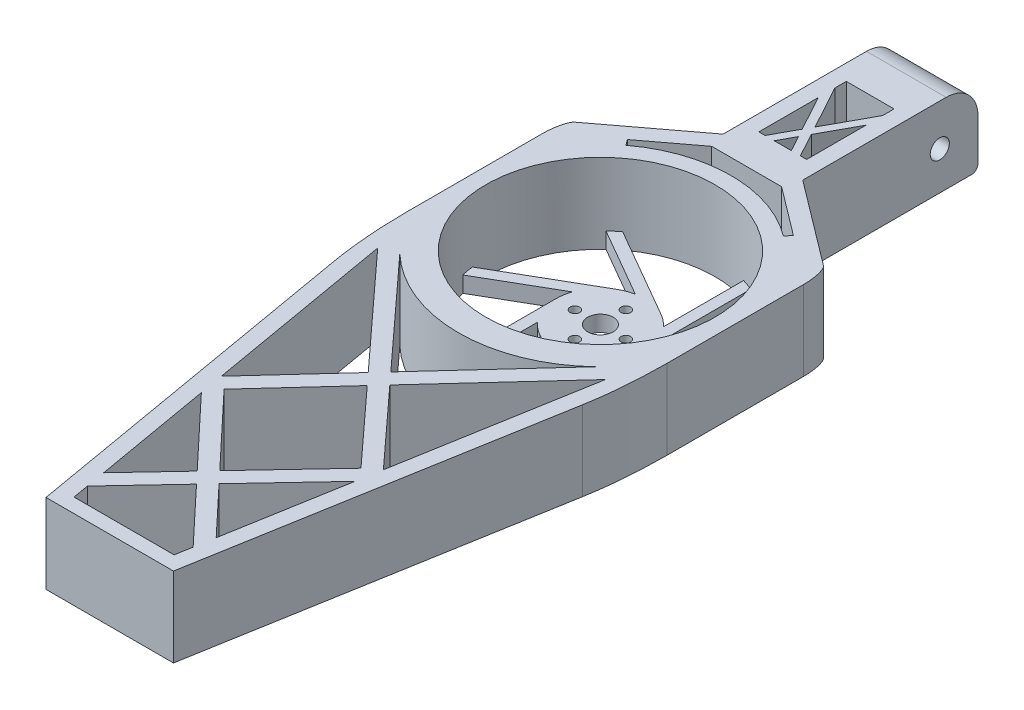
from build123d import *
from build123d.topology import SkipClean

# Parameters (mm, degrees)
SZKIC1_R                    = 1.5
SZKIC1_R_2                  = 4
DODANIE_WYCI_GNI_CIE1_DEPTH = 5
SZKIC1_3_R                  = 36
DODANIE_WYCI_GNI_CIE2_DEPTH = 25
ZAOKR_GLENIE1_R             = 10
ZAOKR_GLENIE2_R             = 2
SZKIC3_R                    = 3
WYTNIJ_WYCI_GNI_CIE2_DEPTH  = 220.010630871
WYTNIJ_WYCI_GNI_CIE3_DEPTH  = 216.983000337
WYTNIJ_WYCI_GNI_CIE4_DEPTH  = 217.503248093
WYTNIJ_WYCI_GNI_CIE5_DEPTH  = 217.503248093
DODANIE_WYCI_GNI_CIE3_DEPTH = 25


with BuildPart() as part:
    # Szkic1 → Dodanie-wyci_gni_cie1 (new body)
    with BuildSketch(Plane(origin=(0, 0, 0), x_dir=(1, 0, 0), z_dir=(0, 1, 0))):
        Polygon((-39.5, 60.773175281), (-20.5, -48.6036745), (19.5, -48.6036745), (38.5, 60.773175281), (38.5, 136.3963255), (12, 156.3963255), (12, 211.3963255), (-13, 211.3963255), (-13, 156.3963255), (-39.5, 136.3963255), align=None)
        with BuildLine():
            ThreePointArc((24.198683142, 138.122080663), (-0.5, 146.3963255), (-25.198683142, 138.122080663))
            Line((-25.198683142, 138.122080663), (-26.54670895, 139.908214858))
            Line((-26.54670895, 139.908214858), (-11.466042799, 151.289849688))
            Line((-11.466042799, 151.289849688), (10.466042799, 151.289849688))
            Line((10.466042799, 151.289849688), (25.54670895, 139.908214858))
            Line((25.54670895, 139.908214858), (24.198683142, 138.122080663))
        make_face(mode=Mode.SUBTRACT)
        with Locations((7.5, 105.3963255)):
            Circle(SZKIC1_R, mode=Mode.SUBTRACT)
        with Locations((-0.5, 97.3963255)):
            Circle(SZKIC1_R, mode=Mode.SUBTRACT)
        with Locations((-8.5, 105.3963255)):
            Circle(SZKIC1_R, mode=Mode.SUBTRACT)
        with Locations((-0.5, 105.3963255)):
            Circle(SZKIC1_R_2, mode=Mode.SUBTRACT)
        with Locations((-0.5, 113.3963255)):
            Circle(SZKIC1_R, mode=Mode.SUBTRACT)
    extrude(amount=DODANIE_WYCI_GNI_CIE1_DEPTH)

    # Szkic1_3 → Dodanie-wyci_gni_cie2 (add)
    with BuildSketch(Plane(origin=(0, 0, 0), x_dir=(1, 0, 0), z_dir=(0, 1, 0))):
        Polygon((-39.5, 60.773175281), (-20.5, -48.6036745), (19.5, -48.6036745), (38.5, 60.773175281), (38.5, 136.3963255), (12, 156.3963255), (12, 211.3963255), (-13, 211.3963255), (-13, 156.3963255), (-39.5, 136.3963255), align=None)
        with Locations((-0.5, 105.3963255)):
            Circle(SZKIC1_3_R, mode=Mode.SUBTRACT)
        with BuildLine():
            ThreePointArc((24.198683142, 138.122080663), (-0.5, 146.3963255), (-25.198683142, 138.122080663))
            Line((-25.198683142, 138.122080663), (-26.54670895, 139.908214858))
            Line((-26.54670895, 139.908214858), (-11.466042799, 151.289849688))
            Line((-11.466042799, 151.289849688), (10.466042799, 151.289849688))
            Line((10.466042799, 151.289849688), (25.54670895, 139.908214858))
            Line((25.54670895, 139.908214858), (24.198683142, 138.122080663))
        make_face(mode=Mode.SUBTRACT)
    extrude(amount=DODANIE_WYCI_GNI_CIE2_DEPTH)

    # Zaokr_glenie1
    zaokr_glenie1_edges = [part.edges().sort_by_distance(p)[0] for p in [
        (-0.5, 25, -211.3963255),
    ]]
    fillet(zaokr_glenie1_edges, radius=ZAOKR_GLENIE1_R)

    # Zaokr_glenie2
    zaokr_glenie2_edges = [part.edges().sort_by_distance(p)[0] for p in [
        (-0.5, 0, -211.3963255),
    ]]
    fillet(zaokr_glenie2_edges, radius=ZAOKR_GLENIE2_R)

    # Szkic3 → Wytnij-wyci_gni_cie2 (cut, through all)
    with BuildSketch(Plane.ZY.offset(13)):
        with Locations((-199.3963255, 12)):
            Circle(SZKIC3_R)
    extrude(amount=-WYTNIJ_WYCI_GNI_CIE2_DEPTH, mode=Mode.SUBTRACT)

    # Szkic4 → Wytnij-wyci_gni_cie3 (cut, through all)
    with SkipClean():  # the faces are left unmerged after this step: merging them gives an invalid solid
        with BuildSketch(Plane(origin=(0, 5, 0), x_dir=(1, 0, 0), z_dir=(0, 1, 0))):
            with BuildLine():
                Line((13.5, 138.562573403), (13.5, 105.3963255))
                ThreePointArc((13.5, 105.3963255), (13.316169956, 103.135032123), (12.769507466, 100.933123554))
                Line((12.769507466, 100.933123554), (34.571343028, 113.520419185))
                ThreePointArc((34.571343028, 113.520419185), (27.045898944, 128.57440677), (13.5, 138.562573403))
            make_face()
            with BuildLine():
                ThreePointArc((6.5, 117.520681153), (8.366422488, 116.230832976), (10, 114.656455088))
                Line((10, 114.656455088), (10, 139.831046349))
                ThreePointArc((10, 139.831046349), (-6.799857719, 140.84081439), (-22.222813233, 134.103805104))
                Line((-22.222813233, 134.103805104), (6.5, 117.520681153))
            make_face()
            with BuildLine():
                Line((35.222813233, 109.855093798), (6.5, 93.271969847))
                ThreePointArc((6.5, 93.271969847), (4.449747468, 92.300524646), (2.269507466, 91.672993965))
                Line((2.269507466, 91.672993965), (24.071343028, 79.085698335))
                ThreePointArc((24.071343028, 79.085698335), (33.345756663, 93.129917879), (35.222813233, 109.855093798))
            make_face()
            with BuildLine():
                ThreePointArc((-7.5, 117.520681153), (-5.449747468, 118.492126353), (-3.269507466, 119.119657034))
                Line((-3.269507466, 119.119657034), (-25.071343028, 131.706952664))
                ThreePointArc((-25.071343028, 131.706952664), (-34.345756663, 117.66273312), (-36.222813233, 100.937557201))
                Line((-36.222813233, 100.937557201), (-7.5, 117.520681153))
            make_face()
            with BuildLine():
                Line((21.222813233, 76.688845895), (-7.5, 93.271969847))
                ThreePointArc((-7.5, 93.271969847), (-9.366422488, 94.561818023), (-11, 96.136195911))
                Line((-11, 96.136195911), (-11, 70.96160465))
                ThreePointArc((-11, 70.96160465), (5.799857719, 69.951836609), (21.222813233, 76.688845895))
            make_face()
            with BuildLine():
                ThreePointArc((-14.5, 105.3963255), (-14.316169956, 107.657618877), (-13.769507466, 109.859527445))
                Line((-13.769507466, 109.859527445), (-35.571343028, 97.272231814))
                ThreePointArc((-35.571343028, 97.272231814), (-28.045898944, 82.218244229), (-14.5, 72.230077596))
                Line((-14.5, 72.230077596), (-14.5, 105.3963255))
            make_face()
        extrude(amount=-WYTNIJ_WYCI_GNI_CIE3_DEPTH, mode=Mode.SUBTRACT)

    # Szkic5 → Wytnij-wyci_gni_cie4 (cut, through all)
    with SkipClean():  # the faces are left unmerged after this step: merging them gives an invalid solid
        with BuildSketch(Plane(origin=(0, 25, 0), x_dir=(1, 0, 0), z_dir=(0, 1, 0))):
            Polygon((-0.5, 167.537901521), (-3.188590085, 162.617610716), (2.188590085, 162.617610716), align=None)
            Polygon((-8, 162.617610716), (-6.037476669, 162.617610716), (-1.924443292, 170.144723317), (-8, 181.2633784), align=None)
            Polygon((0.924443292, 170.144723317), (5.037476669, 162.617610716), (7, 162.617610716), (7, 181.2633784), align=None)
            Polygon((-8, 186.477021992), (-0.5, 172.751545113), (7, 186.477021992), (7, 190.068564472), (-8, 190.068564472), align=None)
        extrude(amount=-WYTNIJ_WYCI_GNI_CIE4_DEPTH, mode=Mode.SUBTRACT)

    # Szkic6 → Wytnij-wyci_gni_cie5 (cut, through all)
    with SkipClean():  # the faces are left unmerged after this step: merging them gives an invalid solid
        with BuildSketch(Plane(origin=(0, 25, 0), x_dir=(1, 0, 0), z_dir=(0, 1, 0))):
            Polygon((2.890112786, 35.914234697), (24.927207854, 11.853436604), (35.243006097, 71.238147911), align=None)
            Polygon((2.931825406, -17.721341562), (17.161306881, -32.852341508), (23.609193637, 4.266055389), align=None)
            Polygon((-36.243006097, 71.238147911), (-25.927207854, 11.853436604), (-3.890112786, 35.914234697), align=None)
            Polygon((-24.609193637, 4.266055389), (-18.161306881, -32.852341508), (-3.931825406, -17.721341562), align=None)
            Polygon((-0.5, -21.370592599), (-17.091150305, -39.01288651), (-16.206822662, -44.1036745), (15.206822662, -44.1036745), (16.091150305, -39.01288651), align=None)
            Polygon((20.976041499, 8.764580183), (-0.5, 32.212802226), (-21.976041499, 8.764580183), (-0.5, -14.072090524), align=None)
            with BuildLine():
                Line((-31.262410293, 73.203040667), (-0.5, 39.615667168))
                Line((-0.5, 39.615667168), (30.262410293, 73.203040667))
                ThreePointArc((30.262410293, 73.203040667), (-0.5, 60.868430026), (-31.262410293, 73.203040667))
            make_face()
        extrude(amount=-WYTNIJ_WYCI_GNI_CIE5_DEPTH, mode=Mode.SUBTRACT)

    # Szkic7 → Dodanie-wyci_gni_cie3 (add)
    with SkipClean():  # the faces are left unmerged after this step: merging them gives an invalid solid
        with BuildSketch(Plane.XZ):
            with BuildLine():
                Line((40.5, -128.178388263), (40.5, -85.340764579))
                add(Edge.make_bspline(
                    [(40.5, -85.340764579), (40.5, -72.286527889), (38.5, -60.773175281)],
                    knots=[1.478281608, 1.478281608, 1.478281608, 2.061293097, 2.061293097, 2.061293097], degree=2, weights=[1, 0.957812218, 1]))
                Line((38.5, -60.773175281), (38.5, -136.3963255))
                add(Edge.make_bspline(
                    [(38.5, -136.3963255), (40.5, -134.886891537), (40.5, -128.178388263)],
                    knots=[3.382541088, 3.382541088, 3.382541088, 4.954548483, 4.954548483, 4.954548483], degree=2, weights=[1, 0.706678474, 1]))
            make_face()
            with BuildLine():
                Line((-39.5, -136.3963255), (-39.5, -60.773175281))
                add(Edge.make_bspline(
                    [(-39.5, -60.773175281), (-41.5, -72.286527889), (-41.5, -85.340764579)],
                    knots=[4.22189221, 4.22189221, 4.22189221, 4.804903699, 4.804903699, 4.804903699], degree=2, weights=[1, 0.957812218, 1]))
                Line((-41.5, -85.340764579), (-41.5, -128.178388263))
                add(Edge.make_bspline(
                    [(-41.5, -128.178388263), (-41.5, -134.886891537), (-39.5, -136.3963255)],
                    knots=[1.328636824, 1.328636824, 1.328636824, 2.900644219, 2.900644219, 2.900644219], degree=2, weights=[1, 0.706678474, 1]))
            make_face()
        extrude(amount=-DODANIE_WYCI_GNI_CIE3_DEPTH)


solid = part.part
